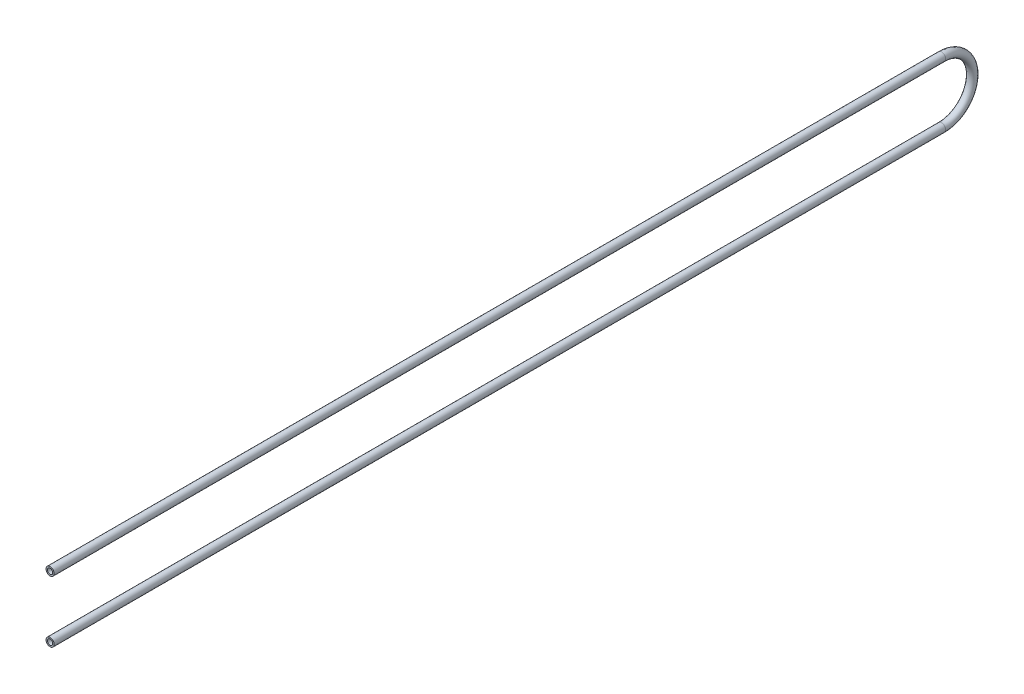
from build123d import *

# Parameters (mm, degrees)
SKETCH2_R   = 10.65
SKETCH2_R_2 = 6.92


with BuildPart() as part:
    # Sweep1: sweep along a path in Sketch1
    with BuildLine(Plane(origin=(0, 0, 0), x_dir=(0, 0, -1), z_dir=(1, 0, 0))) as sweep1_path:
        Line((0, 80), (2325, 80))
        ThreePointArc((2325, 80), (2405, 0), (2325, -80))
        Line((2325, -80), (0, -80))
    # Sketch2 → Sweep1 (sweep)
    with BuildSketch(Plane.XY):
        with Locations((0, 80)):
            Circle(SKETCH2_R)
        with Locations((0, 80)):
            Circle(SKETCH2_R_2, mode=Mode.SUBTRACT)
    sweep(path=sweep1_path.line)


solid = part.part
